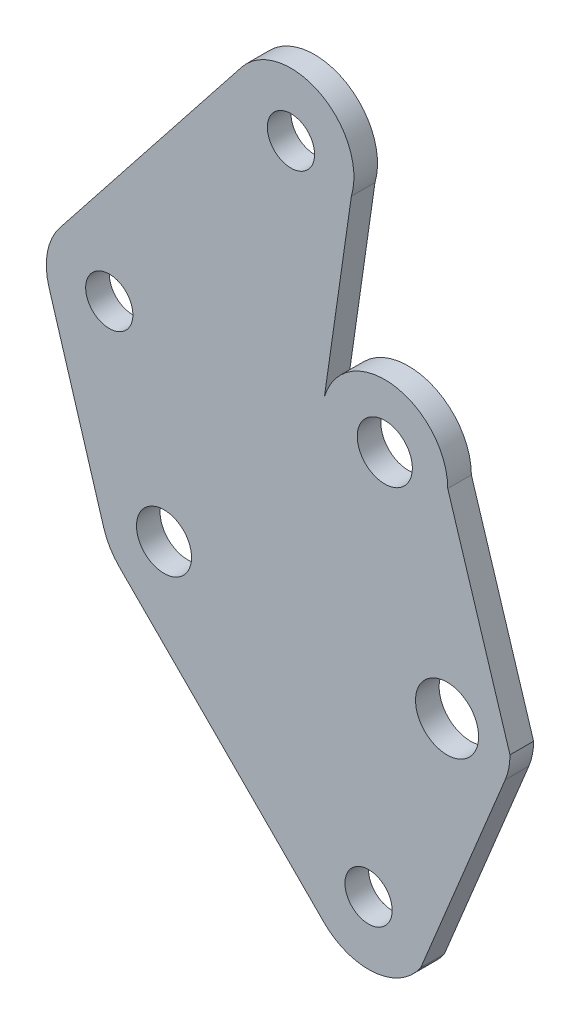
from build123d import *

# Parameters (mm, degrees)
SKETCH_1_R      = 1.5
SKETCH_1_R_2    = 1.75
SKETCH_1_R_3    = 2.003944014
EXTRUDE_1_DEPTH = 1.5


with BuildPart() as part:
    # 草图1 → 凸台-拉伸1 (new body)
    with BuildSketch(Plane.XY):
        with BuildLine():
            Line((494.605769137, -527.839196558), (481.609593026, -514.791054036))
            ThreePointArc((481.609593026, -514.791054036), (481.010170453, -514.02038782), (480.615305213, -513.127462695))
            Line((480.615305213, -513.127462695), (477.137746123, -501.642402546))
            ThreePointArc((477.137746123, -501.642402546), (477.036205762, -499.737604009), (477.82836441, -498.002365526))
            Line((477.82836441, -498.002365526), (489.371543171, -483.402763587))
            ThreePointArc((489.371543171, -483.402763587), (494.347956643, -482.33084182), (496.347682498, -487.012166828))
            Line((496.347682498, -487.012166828), (494.635210185, -498.909638655))
            ThreePointArc((494.635210185, -498.909638655), (499.042707903, -496.078572348), (502.472829473, -500.037769057))
            Line((502.472829473, -500.037769057), (506.42586238, -512.71203188))
            ThreePointArc((506.42586238, -512.71203188), (506.349706324, -513.4886139), (506.124139786, -514.235607285))
            Line((506.124139786, -514.235607285), (500.760627906, -527.246291449))
            ThreePointArc((500.760627906, -527.246291449), (497.823383917, -528.997987509), (494.605769137, -527.839196558))
        make_face()
        with Locations((480.966099189, -500.483216279)):
            Circle(SKETCH_1_R, mode=Mode.SUBTRACT)
        with Locations((484.443657551, -511.968276648)):
            Circle(SKETCH_1_R_2, mode=Mode.SUBTRACT)
        with Locations((492.509632998, -485.883895059)):
            Circle(SKETCH_1_R, mode=Mode.SUBTRACT)
        with Locations((502.428285494, -512.71203188)):
            Circle(SKETCH_1_R_3, mode=Mode.SUBTRACT)
        with Locations((497.439834468, -525.016418366)):
            Circle(SKETCH_1_R, mode=Mode.SUBTRACT)
        with Locations((498.472829473, -500.037769057)):
            Circle(SKETCH_1_R_2, mode=Mode.SUBTRACT)
    extrude(amount=EXTRUDE_1_DEPTH)


solid = part.part
